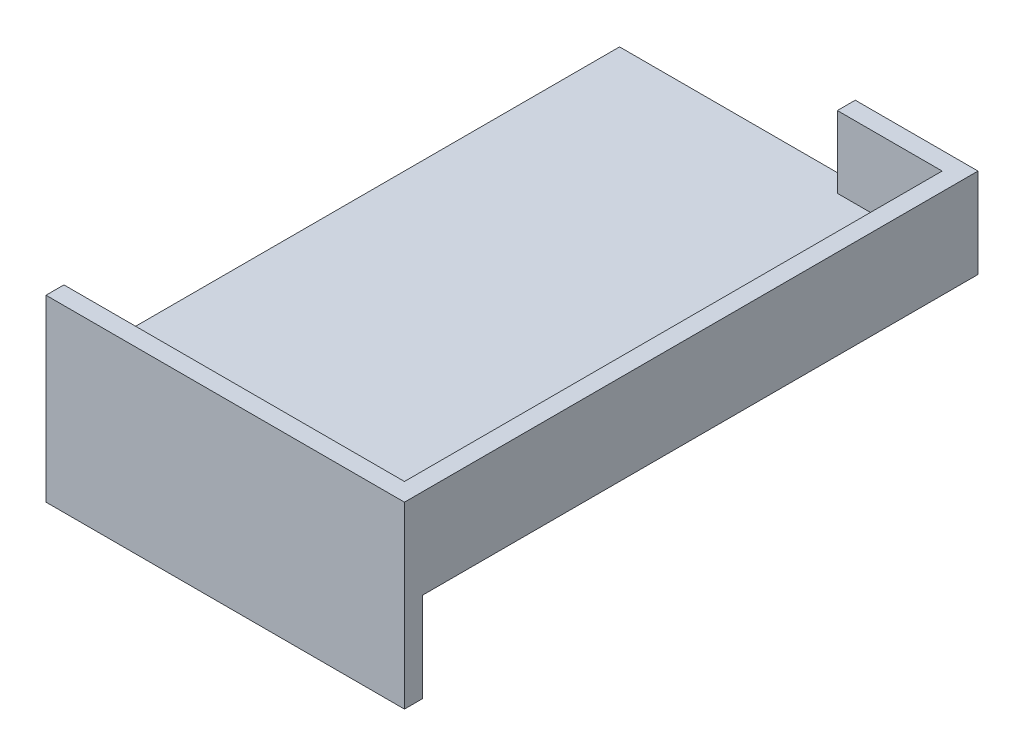
from build123d import *

# Parameters (mm, degrees)
SKETCH1_W           = 100
SKETCH1_H           = 160
BOSS_EXTRUDE1_DEPTH = 5
SKETCH2_W           = 100
SKETCH2_H           = 50
BOSS_EXTRUDE2_DEPTH = 5
SKETCH4_W           = 160
SKETCH4_H           = 25
BOSS_EXTRUDE3_DEPTH = 5
SKETCH5_W           = 34.236688448
SKETCH5_H           = 25
BOSS_EXTRUDE4_DEPTH = 5


with BuildPart() as part:
    # Sketch1 → Boss-Extrude1 (new body)
    with BuildSketch(Plane(origin=(0, 0, 0), x_dir=(1, 0, 0), z_dir=(0, 1, 0))):
        with Locations((0, 80)):
            Rectangle(SKETCH1_W, SKETCH1_H)
    extrude(amount=BOSS_EXTRUDE1_DEPTH)

    # Sketch2 → Boss-Extrude2 (add)
    with BuildSketch(Plane.XY):
        Rectangle(SKETCH2_W, SKETCH2_H)
    extrude(amount=-BOSS_EXTRUDE2_DEPTH)

    # Sketch4 → Boss-Extrude3 (add)
    with BuildSketch(Plane(origin=(50, 0, 0), x_dir=(0, 0, -1), z_dir=(1, 0, 0))):
        with Locations((80, 12.5)):
            Rectangle(SKETCH4_W, SKETCH4_H)
    extrude(amount=-BOSS_EXTRUDE3_DEPTH)

    # Sketch5 → Boss-Extrude4 (add)
    with BuildSketch(Plane(origin=(0, 0, -160), x_dir=(-1, 0, 0), z_dir=(0, 0, -1))):
        with Locations((-32.881655776, 12.5)):
            Rectangle(SKETCH5_W, SKETCH5_H)
    extrude(amount=-BOSS_EXTRUDE4_DEPTH)


solid = part.part
